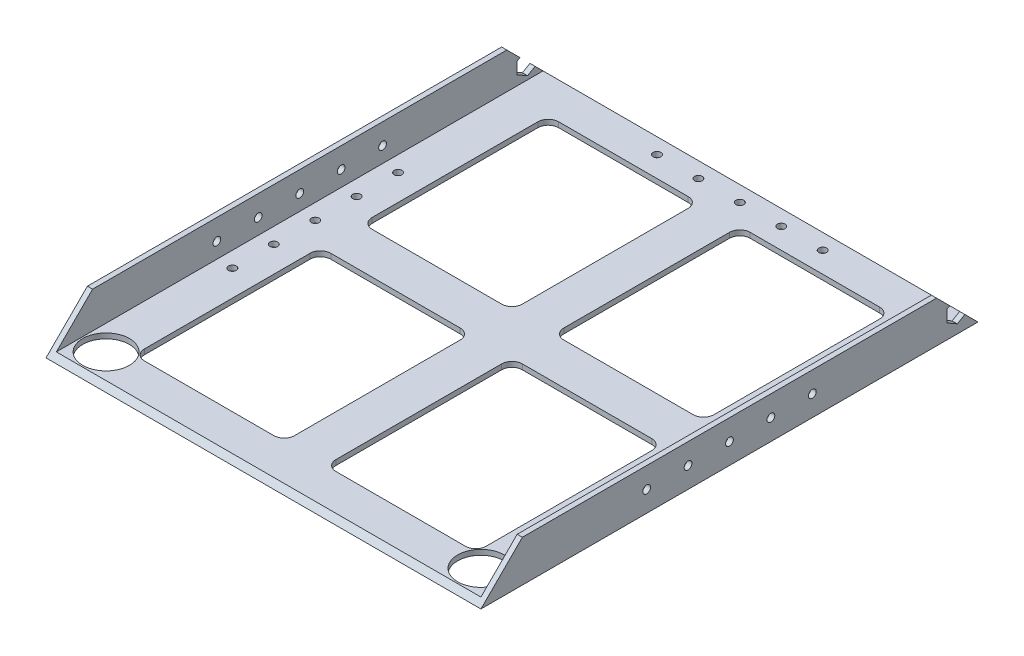
from build123d import *

# Parameters (mm, degrees)
SKETCH1_W           = 266.7
SKETCH1_H           = 304.8
BOSS_EXTRUDE1_DEPTH = 25.4
SKETCH2_W           = 260.35
SKETCH2_H           = 22.225
CUT_EXTRUDE1_DEPTH  = 12700
CUT_EXTRUDE2_DEPTH  = 12700
CUT_EXTRUDE10_DEPTH = 12700
SKETCH5_R           = 2.38125
CUT_EXTRUDE11_DEPTH = 267.7
SKETCH6_R           = 2.38125
CUT_EXTRUDE12_DEPTH = 4.175
SKETCH7_R           = 14.2875
CUT_EXTRUDE13_DEPTH = 3.175
SKETCH8_R           = 2.38125
CUT_EXTRUDE14_DEPTH = 4.175
CUT_EXTRUDE15_DEPTH = 267.7


with BuildPart() as part:
    # Sketch1 → Boss-Extrude1 (new body)
    with BuildSketch(Plane(origin=(0, 0, 0), x_dir=(1, 0, 0), z_dir=(0, 1, 0))):
        with Locations((46.828595318, 35.997491639)):
            Rectangle(SKETCH1_W, SKETCH1_H)
    extrude(amount=BOSS_EXTRUDE1_DEPTH)

    # Sketch2 → Cut-Extrude1 (cut)
    with BuildSketch(Plane.XY.offset(116.402508361)):
        with Locations((46.828595318, 14.2875)):
            Rectangle(SKETCH2_W, SKETCH2_H)
    extrude(amount=-CUT_EXTRUDE1_DEPTH, mode=Mode.SUBTRACT)

    # Sketch3 → Cut-Extrude2 (cut)
    with BuildSketch(Plane(origin=(0, 3.175, 0), x_dir=(1, 0, 0), z_dir=(0, 1, 0))):
        with BuildLine():
            ThreePointArc((65.878595318, -91.002508361), (61.388467257, -89.142636422), (59.528595318, -84.652508361))
            Line((59.528595318, -84.652508361), (59.528595318, 16.947491639))
            ThreePointArc((59.528595318, 16.947491639), (61.388467257, 21.437619699), (65.878595318, 23.297491639))
            Line((65.878595318, 23.297491639), (145.253595318, 23.297491639))
            ThreePointArc((145.253595318, 23.297491639), (149.743723378, 21.437619699), (151.603595318, 16.947491639))
            Line((151.603595318, 16.947491639), (151.603595318, -84.652508361))
            ThreePointArc((151.603595318, -84.652508361), (149.743723378, -89.142636422), (145.253595318, -91.002508361))
            Line((145.253595318, -91.002508361), (65.878595318, -91.002508361))
        make_face()
        with BuildLine():
            ThreePointArc((145.253595318, 162.997491639), (149.743723378, 161.137619699), (151.603595318, 156.647491639))
            Line((151.603595318, 156.647491639), (151.603595318, 55.047491639))
            ThreePointArc((151.603595318, 55.047491639), (149.743723378, 50.557363578), (145.253595318, 48.697491639))
            Line((145.253595318, 48.697491639), (65.878595318, 48.697491639))
            ThreePointArc((65.878595318, 48.697491639), (61.388467257, 50.557363578), (59.528595318, 55.047491639))
            Line((59.528595318, 55.047491639), (59.528595318, 156.647491639))
            ThreePointArc((59.528595318, 156.647491639), (61.388467257, 161.137619699), (65.878595318, 162.997491639))
            Line((65.878595318, 162.997491639), (145.253595318, 162.997491639))
        make_face()
        with BuildLine():
            ThreePointArc((27.778595318, 162.997491639), (32.268723378, 161.137619699), (34.128595318, 156.647491639))
            Line((34.128595318, 156.647491639), (34.128595318, 55.047491639))
            ThreePointArc((34.128595318, 55.047491639), (32.268723378, 50.557363578), (27.778595318, 48.697491639))
            Line((27.778595318, 48.697491639), (-51.596404682, 48.697491639))
            ThreePointArc((-51.596404682, 48.697491639), (-56.086532743, 50.557363578), (-57.946404682, 55.047491639))
            Line((-57.946404682, 55.047491639), (-57.946404682, 156.647491639))
            ThreePointArc((-57.946404682, 156.647491639), (-56.086532743, 161.137619699), (-51.596404682, 162.997491639))
            Line((-51.596404682, 162.997491639), (27.778595318, 162.997491639))
        make_face()
        with BuildLine():
            Line((-57.946404682, -84.652508361), (-57.946404682, 16.947491639))
            ThreePointArc((-57.946404682, 16.947491639), (-56.086532743, 21.437619699), (-51.596404682, 23.297491639))
            Line((-51.596404682, 23.297491639), (27.778595318, 23.297491639))
            ThreePointArc((27.778595318, 23.297491639), (32.268723378, 21.437619699), (34.128595318, 16.947491639))
            Line((34.128595318, 16.947491639), (34.128595318, -84.652508361))
            ThreePointArc((34.128595318, -84.652508361), (32.268723378, -89.142636422), (27.778595318, -91.002508361))
            Line((27.778595318, -91.002508361), (-51.596404682, -91.002508361))
            ThreePointArc((-51.596404682, -91.002508361), (-56.086532743, -89.142636422), (-57.946404682, -84.652508361))
        make_face()
    extrude(amount=-CUT_EXTRUDE2_DEPTH, mode=Mode.SUBTRACT)

    # Sketch4 → Cut-Extrude10 (cut)
    with BuildSketch(Plane(origin=(180.178595318, 0, 0), x_dir=(0, 0, -1), z_dir=(1, 0, 0))):
        Polygon((162.997491639, 25.4), (188.397491639, 0), (188.397491639, 25.4), align=None)
        Polygon((-116.402508361, 0), (-91.002508361, 25.4), (-116.402508361, 25.4), align=None)
    extrude(amount=-CUT_EXTRUDE10_DEPTH, mode=Mode.SUBTRACT)

    # Sketch5 → Cut-Extrude11 (cut, through all)
    with BuildSketch(Plane(origin=(180.178595318, 0, 0), x_dir=(0, 0, -1), z_dir=(1, 0, 0))):
        with Locations((86.797491639, 12.7)):
            Circle(SKETCH5_R)
        with Locations((35.997491639, 12.7)):
            Circle(SKETCH5_R)
        with Locations((61.397491639, 12.7)):
            Circle(SKETCH5_R)
        with Locations((10.597491639, 12.7)):
            Circle(SKETCH5_R)
        with Locations((-14.802508361, 12.7)):
            Circle(SKETCH5_R)
    extrude(amount=-CUT_EXTRUDE11_DEPTH, mode=Mode.SUBTRACT)

    # Sketch6 → Cut-Extrude12 (cut, through all)
    with BuildSketch(Plane(origin=(0, 3.175, 0), x_dir=(1, 0, 0), z_dir=(0, 1, 0))):
        with Locations((46.828595318, 175.697491639)):
            Circle(SKETCH6_R)
        with Locations((21.428595318, 175.697491639)):
            Circle(SKETCH6_R)
        with Locations((-3.971404682, 175.697491639)):
            Circle(SKETCH6_R)
        with Locations((72.228595318, 175.697491639)):
            Circle(SKETCH6_R)
        with Locations((97.628595318, 175.697491639)):
            Circle(SKETCH6_R)
    extrude(amount=-CUT_EXTRUDE12_DEPTH, mode=Mode.SUBTRACT)

    # Sketch7 → Cut-Extrude13 (cut)
    with BuildSketch(Plane(origin=(0, 3.175, 0), x_dir=(1, 0, 0), z_dir=(0, 1, 0))):
        with Locations((-68.106404682, -97.987508361)):
            Circle(SKETCH7_R)
        with Locations((161.763595318, -97.987508361)):
            Circle(SKETCH7_R)
    extrude(amount=-CUT_EXTRUDE13_DEPTH, mode=Mode.SUBTRACT)

    # Sketch8 → Cut-Extrude14 (cut, through all)
    with BuildSketch(Plane(origin=(0, 3.175, 0), x_dir=(1, 0, 0), z_dir=(0, 1, 0))):
        with Locations((167.478595318, 35.997491639)):
            Circle(SKETCH8_R)
        with Locations((167.478595318, 61.397491639)):
            Circle(SKETCH8_R)
        with Locations((167.478595318, 86.797491639)):
            Circle(SKETCH8_R)
        with Locations((167.478595318, 10.597491639)):
            Circle(SKETCH8_R)
        with Locations((167.478595318, -14.802508361)):
            Circle(SKETCH8_R)
        with Locations((-73.821404682, -14.802508361)):
            Circle(SKETCH8_R)
        with Locations((-73.821404682, 10.597491639)):
            Circle(SKETCH8_R)
        with Locations((-73.821404682, 35.997491639)):
            Circle(SKETCH8_R)
        with Locations((-73.821404682, 61.397491639)):
            Circle(SKETCH8_R)
        with Locations((-73.821404682, 86.797491639)):
            Circle(SKETCH8_R)
    extrude(amount=-CUT_EXTRUDE14_DEPTH, mode=Mode.SUBTRACT)

    # Sketch9 → Cut-Extrude15 (cut, through all)
    with BuildSketch(Plane.ZY.offset(86.521404682)):
        Polygon((-175.697491639, 20.032348419), (-182.047491639, 16.366174209), (-182.047491639, 9.033825791), (-175.697491639, 5.367651581), (-169.347491639, 9.033825791), (-169.347491639, 16.366174209), align=None)
    extrude(amount=-CUT_EXTRUDE15_DEPTH, mode=Mode.SUBTRACT)


solid = part.part
